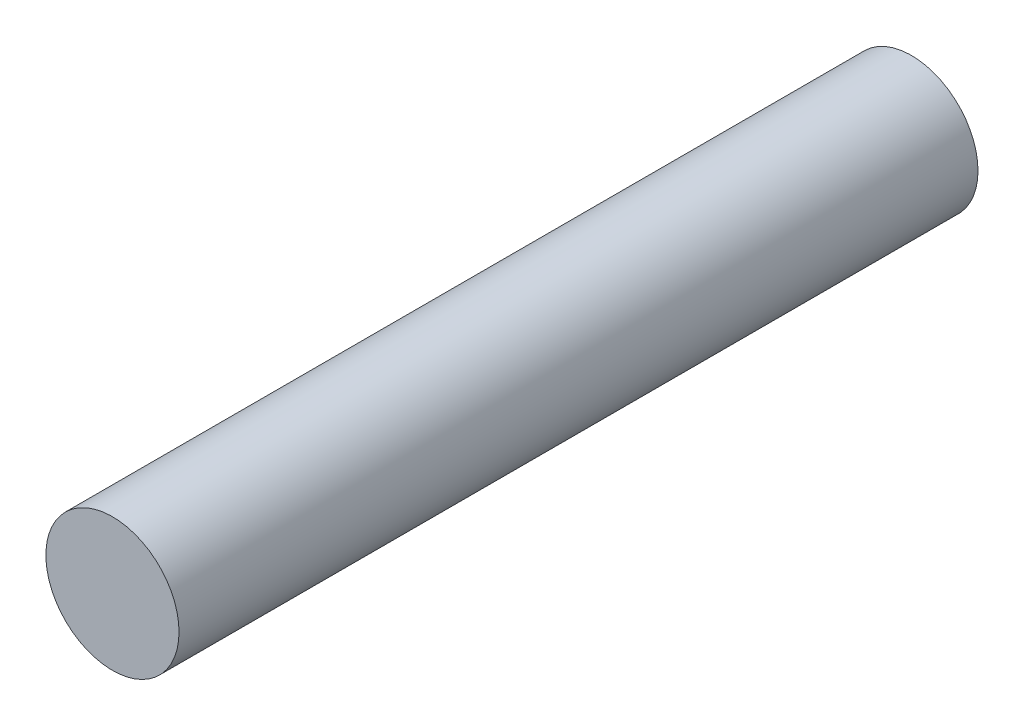
from build123d import *

# Parameters (mm, degrees)
SKETCH1_R           = 0.5
BOSS_EXTRUDE1_DEPTH = 6


with BuildPart() as part:
    # Sketch1 → Boss-Extrude1 (new body)
    with BuildSketch(Plane.XY):
        Circle(SKETCH1_R)
    extrude(amount=BOSS_EXTRUDE1_DEPTH)


solid = part.part
